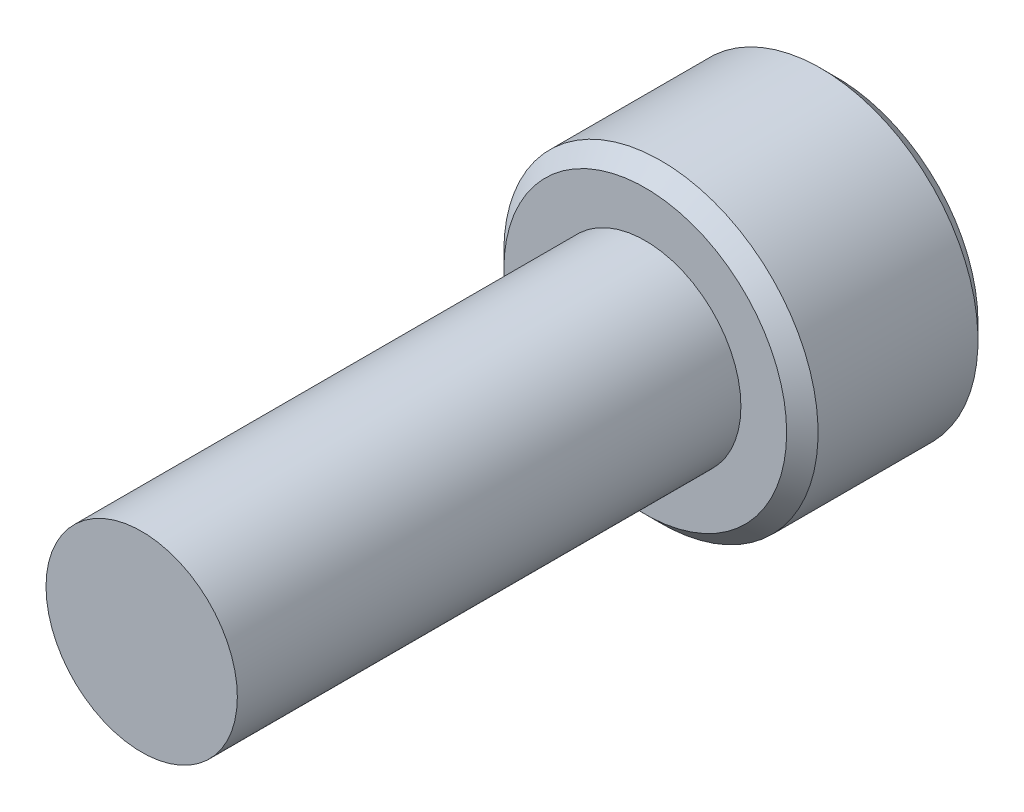
from build123d import *

# Parameters (mm, degrees)
SKETCH1_R          = 2.413
EXTRUDE1_DEPTH     = 12.7
SKETCH6_R          = 3.9624
EXTRUDE2_DEPTH     = 4.826
CUT_EXTRUDE1_DEPTH = 2.9765625
CHAMFER1_SIZE      = 0.39624


with BuildPart() as part:
    # Sketch1 → Extrude1 (new body)
    with BuildSketch(Plane.XY):
        Circle(SKETCH1_R)
    extrude(amount=-EXTRUDE1_DEPTH)

    # Sketch6 → Extrude2 (add)
    with BuildSketch(Plane(origin=(0, 0, -12.7), x_dir=(-1, 0, 0), z_dir=(0, 0, -1))):
        Circle(SKETCH6_R)
    extrude(amount=EXTRUDE2_DEPTH)

    # Sketch7 → Cut-Extrude1 (cut)
    with BuildSketch(Plane(origin=(0, 0, -17.526), x_dir=(-1, 0, 0), z_dir=(0, 0, -1))):
        Polygon((0, 2.291358881), (-1.984375, 1.14567944), (-1.984375, -1.14567944), (0, -2.291358881), (1.984375, -1.14567944), (1.984375, 1.14567944), align=None)
    extrude(amount=-CUT_EXTRUDE1_DEPTH, mode=Mode.SUBTRACT)

    # Cut-Extrude2 cone 1 section (through the dimple's axis) → Cut-Extrude2 (revolve, cut)
    with BuildSketch(Plane(origin=(0, 0, -17.526), x_dir=(0, 1, 0), z_dir=(1, 0, 0))):
        Polygon((0, 0), (2.291358881, 0), (0, 2.291358881), align=None)
    revolve(axis=Axis((0, 0, -17.526), (0, 0, 1)), mode=Mode.SUBTRACT)

    # Chamfer1
    chamfer1_edges = [part.edges().sort_by_distance(p)[0] for p in [
        (3.9624, 0, -12.7),
        (3.9624, 0, -17.526),
    ]]
    chamfer(chamfer1_edges, length=CHAMFER1_SIZE)


solid = part.part
